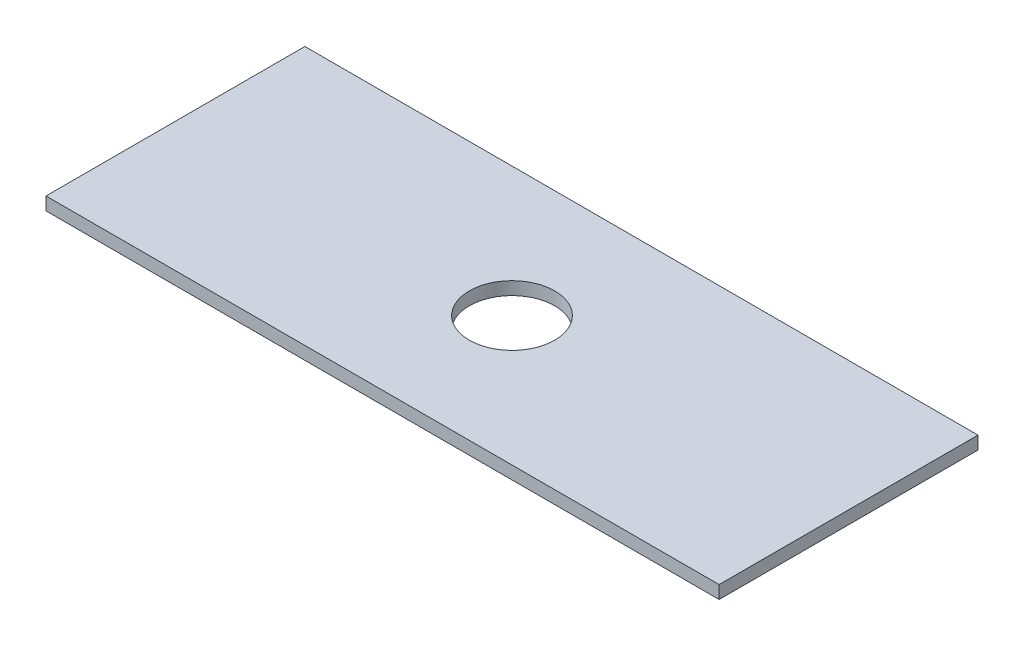
from build123d import *

# Parameters (mm, degrees)
SKETCH1_W           = 130
SKETCH1_H           = 50
SKETCH1_R           = 8.25
BOSS_EXTRUDE1_DEPTH = 2.5


with BuildPart() as part:
    # Sketch1 → Boss-Extrude1 (new body)
    with BuildSketch(Plane(origin=(0, 0, 0), x_dir=(1, 0, 0), z_dir=(0, 1, 0))):
        with Locations((65, 25)):
            Rectangle(SKETCH1_W, SKETCH1_H)
        with Locations((65, 25)):
            Circle(SKETCH1_R, mode=Mode.SUBTRACT)
    extrude(amount=BOSS_EXTRUDE1_DEPTH)


solid = part.part
